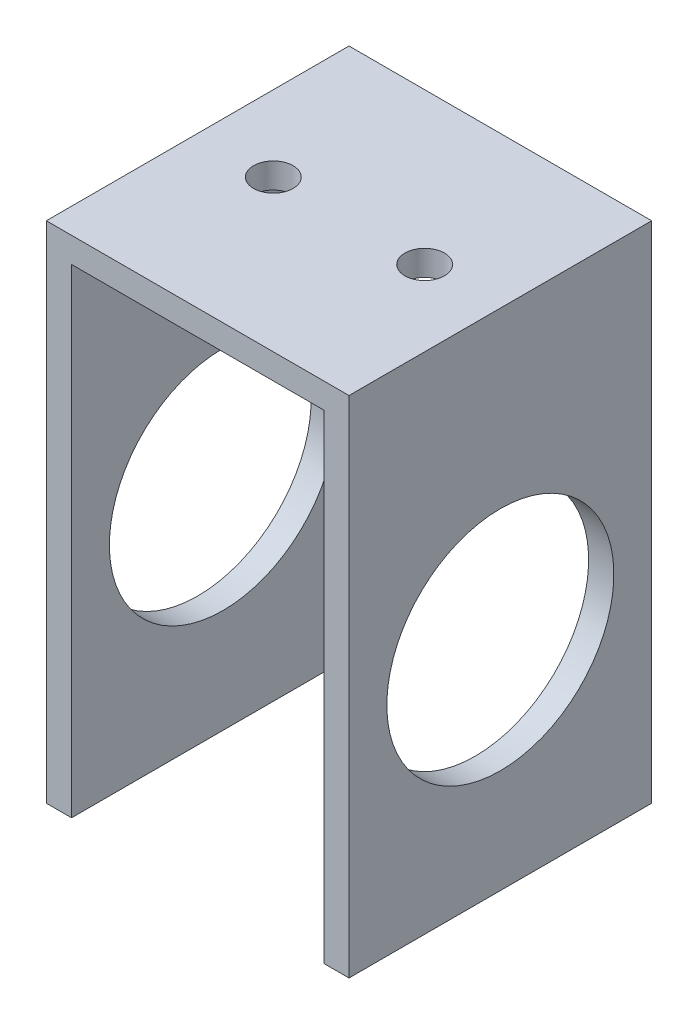
from build123d import *

# Parameters (mm, degrees)
BOSS_EXTRUDE1_DEPTH            = 38.1
SKETCH2_R                      = 14.2875
CUT_EXTRUDE1_DEPTH             = 39.1
F_9_0_196_DIAMETER_HOLE1_D     = 4.9784
F_9_0_196_DIAMETER_HOLE1_DEPTH = 3.175


with BuildPart() as part:
    # Sketch1 → Boss-Extrude1 (new body)
    with BuildSketch(Plane.XY):
        Polygon((-19.05, 0), (19.05, 0), (19.05, -63.5), (15.875, -63.5), (15.875, -3.175), (-15.875, -3.175), (-15.875, -63.5), (-19.05, -63.5), align=None)
    extrude(amount=BOSS_EXTRUDE1_DEPTH)

    # Sketch2 → Cut-Extrude1 (cut, through all)
    with BuildSketch(Plane(origin=(19.05, 0, 0), x_dir=(0, 0, -1), z_dir=(1, 0, 0))):
        with Locations((-19.05, -36.1499912)):
            Circle(SKETCH2_R)
    extrude(amount=-CUT_EXTRUDE1_DEPTH, mode=Mode.SUBTRACT)

    # #9 (0.196) Diameter Hole1
    with Locations(Plane(origin=(0, 0, 0), x_dir=(1, 0, 0), z_dir=(0, 1, 0))):
        with Locations((-9.525, -19.05), (9.525, -19.05)):
            Hole(F_9_0_196_DIAMETER_HOLE1_D / 2, depth=F_9_0_196_DIAMETER_HOLE1_DEPTH)


solid = part.part
